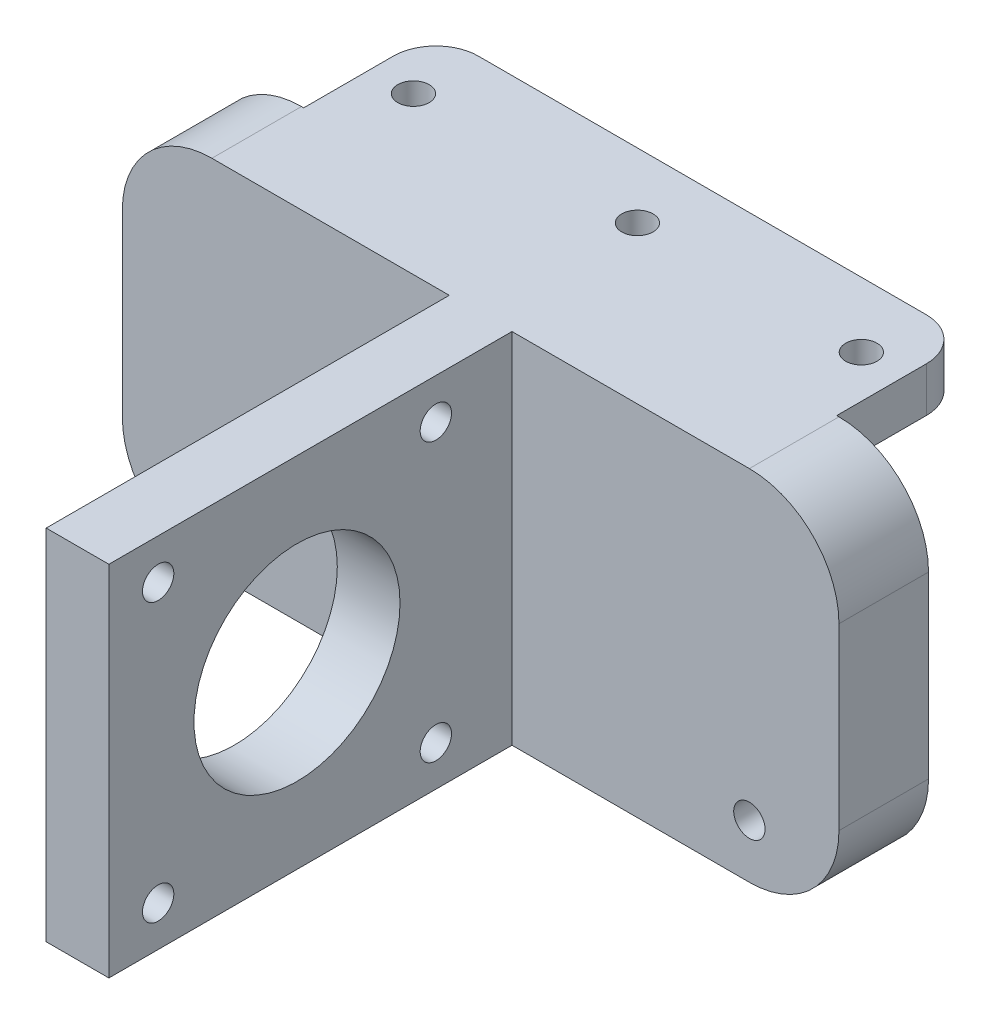
from build123d import *

# Parameters (mm, degrees)
BOSS_EXTRUDE1_DEPTH = 10
SKETCH2_W           = 60
SKETCH2_H           = 5
BOSS_EXTRUDE2_DEPTH = 25
FILLET1_R           = 5
SKETCH3_R           = 1.75
CUT_EXTRUDE1_DEPTH  = 25
SKETCH4_R           = 1.75
CUT_EXTRUDE2_DEPTH  = 25
CUT_EXTRUDE3_DEPTH  = 25
SKETCH6_W           = 7
SKETCH6_H           = 40
BOSS_EXTRUDE3_DEPTH = 45
SKETCH7_R           = 11.5
SKETCH7_R_2         = 1.75
CUT_EXTRUDE4_DEPTH  = 45


with BuildPart() as part:
    # Sketch1 → Boss-Extrude1 (new body)
    with BuildSketch(Plane.XY):
        with BuildLine():
            Line((60, 35), (0, 35))
            Line((0, 35), (0, 40))
            ThreePointArc((0, 40), (-7.071067812, 37.071067812), (-10, 30))
            Line((-10, 30), (-10, 10))
            ThreePointArc((-10, 10), (-7.071067812, 2.928932188), (0, 0))
            Line((0, 0), (60, 0))
            ThreePointArc((60, 0), (67.071067812, 2.928932188), (70, 10))
            Line((70, 10), (70, 30))
            ThreePointArc((70, 30), (67.071067812, 37.071067812), (60, 40))
            Line((60, 40), (60, 35))
        make_face()
    extrude(amount=BOSS_EXTRUDE1_DEPTH)

    # Sketch2 → Boss-Extrude2 (add)
    with BuildSketch(Plane.XY.offset(10)):
        with Locations((30, 37.5)):
            Rectangle(SKETCH2_W, SKETCH2_H)
    extrude(amount=-BOSS_EXTRUDE2_DEPTH)

    # Fillet1
    fillet1_edges = [part.edges().sort_by_distance(p)[0] for p in [
        (0, 37.5, -15),
        (60, 37.5, -15),
    ]]
    fillet(fillet1_edges, radius=FILLET1_R)

    # Sketch3 → Cut-Extrude1 (cut)
    with BuildSketch(Plane.XY.offset(10)):
        with Locations((0, 6)):
            Circle(SKETCH3_R)
        with Locations((60, 6)):
            Circle(SKETCH3_R)
    extrude(amount=-CUT_EXTRUDE1_DEPTH, mode=Mode.SUBTRACT)

    # Sketch4 → Cut-Extrude2 (cut)
    with BuildSketch(Plane(origin=(0, 35, 0), x_dir=(-1, 0, 0), z_dir=(0, -1, 0))):
        with Locations((-55, 7.5)):
            Circle(SKETCH4_R)
        with Locations((-30, 7.5)):
            Circle(SKETCH4_R)
        with Locations((-5, 7.5)):
            Circle(SKETCH4_R)
    extrude(amount=-CUT_EXTRUDE2_DEPTH, mode=Mode.SUBTRACT)

    # Sketch5 → Cut-Extrude3 (cut)
    with BuildSketch(Plane.XZ.offset(-35)):
        with BuildLine():
            Line((5, -14.75), (55, -14.75))
            ThreePointArc((55, -14.75), (58.358757211, -13.358757211), (59.75, -10))
            Line((59.75, -10), (59.75, -0.25))
            Line((59.75, -0.25), (59.75, 0))
            Line((59.75, 0), (60, 0))
            Line((60, 0), (60, -10))
            ThreePointArc((60, -10), (58.535533906, -13.535533906), (55, -15))
            Line((55, -15), (5, -15))
            ThreePointArc((5, -15), (1.464466094, -13.535533906), (0, -10))
            Line((0, -10), (0, 0))
            Line((0, 0), (0.25, 0))
            Line((0.25, 0), (0.25, -0.25))
            Line((0.25, -0.25), (0.25, -10))
            ThreePointArc((0.25, -10), (1.641242789, -13.358757211), (5, -14.75))
        make_face()
    extrude(amount=-CUT_EXTRUDE3_DEPTH, mode=Mode.SUBTRACT)

    # Sketch6 → Boss-Extrude3 (add)
    with BuildSketch(Plane.XY.offset(10)):
        with Locations((30, 20)):
            Rectangle(SKETCH6_W, SKETCH6_H)
    extrude(amount=BOSS_EXTRUDE3_DEPTH)

    # Sketch7 → Cut-Extrude4 (cut)
    with BuildSketch(Plane(origin=(33.5, 0, 0), x_dir=(0, 0, -1), z_dir=(1, 0, 0))):
        with Locations((-34, 20)):
            Circle(SKETCH7_R)
        with Locations((-49.5, 35.5)):
            Circle(SKETCH7_R_2)
        with Locations((-18.5, 35.5)):
            Circle(SKETCH7_R_2)
        with Locations((-18.5, 4.5)):
            Circle(SKETCH7_R_2)
        with Locations((-49.5, 4.5)):
            Circle(SKETCH7_R_2)
    extrude(amount=-CUT_EXTRUDE4_DEPTH, mode=Mode.SUBTRACT)


solid = part.part
